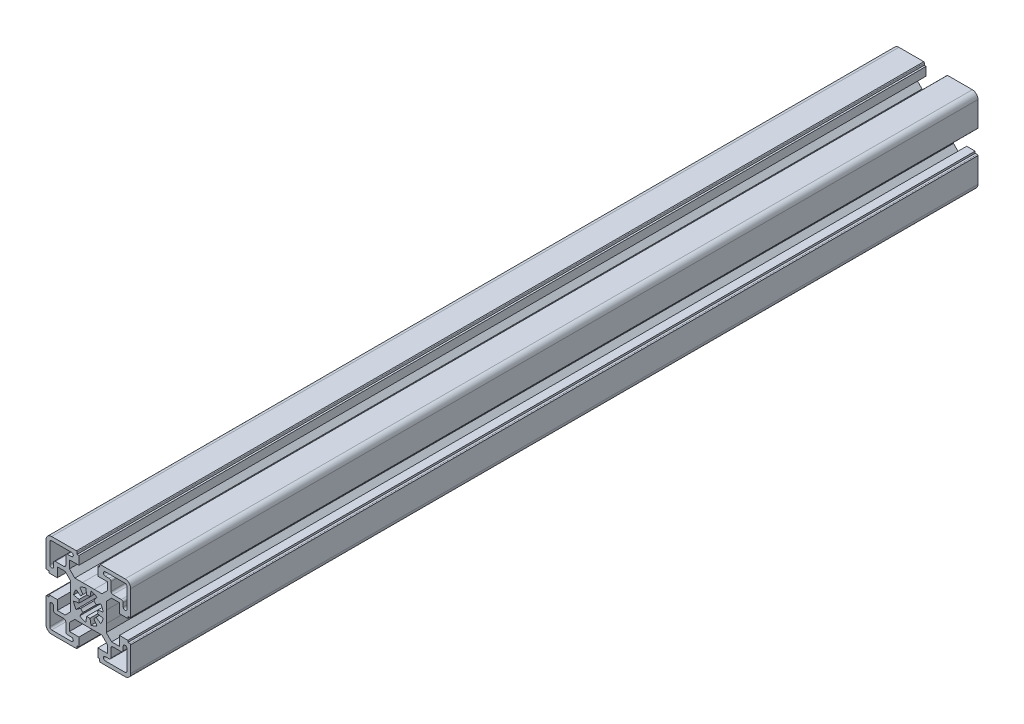
from build123d import *

# Parameters (mm, degrees)
BOSS_EXTRUDE1_DEPTH = 450


with BuildPart() as part:
    # Sketch1 → Boss-Extrude1 (new body)
    with BuildSketch(Plane.XY):
        with BuildLine():
            Line((-9.499953806, 3.122740916), (-9.499953806, 7.206970084))
            Line((-9.499953806, 7.206970084), (-12.342923806, 10.049940084))
            Line((-12.342923806, 10.049940084), (-16.500012806, 10.049940084))
            Line((-16.500012806, 10.049940084), (-16.500012806, 4.999940084))
            Line((-16.500012806, 4.999940084), (-20.999920806, 4.999940084))
            Line((-20.999920806, 4.999940084), (-20.999920806, 6))
            Line((-20.999920806, 6), (-21.99992119, 6))
            ThreePointArc((-21.99992119, 6), (-22.298164639, 6.069539801), (-22.49992067, 6.299929564))
            Line((-22.49992067, 6.299929564), (-22.49992067, 19.500002241))
            ThreePointArc((-22.49992067, 19.500002241), (-21.62124167, 21.621321), (-19.499922911, 22.5))
            Line((-19.499922911, 22.5), (-6.299954884, 22.5))
            ThreePointArc((-6.299954884, 22.5), (-6.069541349, 22.298205758), (-6, 21.999918456))
            Line((-6, 21.999918456), (-6, 20.999918083))
            Line((-6, 20.999918083), (-5, 20.999918083))
            Line((-5, 20.999918083), (-5, 16.499959846))
            Line((-5, 16.499959846), (-10.050086009, 16.499959846))
            Line((-10.050086009, 16.499959846), (-10.050086009, 12.342824291))
            Line((-10.050086009, 12.342824291), (-7.207137036, 9.499875319))
            Line((-7.207137036, 9.499875319), (-3.122784036, 9.499875319))
            Line((-3.122784036, 9.499875319), (3.122740916, 9.499953806))
            Line((3.122740916, 9.499953806), (7.206970084, 9.499953806))
            Line((7.206970084, 9.499953806), (10.049940084, 12.342923806))
            Line((10.049940084, 12.342923806), (10.049940084, 16.500012806))
            Line((10.049940084, 16.500012806), (4.999940084, 16.500012806))
            Line((4.999940084, 16.500012806), (4.999940084, 20.999920806))
            Line((4.999940084, 20.999920806), (6, 20.999920806))
            Line((6, 20.999920806), (6, 21.99992119))
            ThreePointArc((6, 21.99992119), (6.069539801, 22.298164639), (6.299929564, 22.49992067))
            Line((6.299929564, 22.49992067), (19.500002241, 22.49992067))
            ThreePointArc((19.500002241, 22.49992067), (21.621321, 21.62124167), (22.5, 19.499922911))
            Line((22.5, 19.499922911), (22.5, 6.299954884))
            ThreePointArc((22.5, 6.299954884), (22.298205758, 6.069541349), (21.999918456, 6))
            Line((21.999918456, 6), (20.999918083, 6))
            Line((20.999918083, 6), (20.999918083, 5))
            Line((20.999918083, 5), (16.499959846, 5))
            Line((16.499959846, 5), (16.499959846, 10.050086009))
            Line((16.499959846, 10.050086009), (12.342824291, 10.050086009))
            Line((12.342824291, 10.050086009), (9.499875319, 7.207137036))
            Line((9.499875319, 7.207137036), (9.499875319, 3.122784036))
            Line((9.499875319, 3.122784036), (9.499953806, -3.122740916))
            Line((9.499953806, -3.122740916), (9.499953806, -7.206970084))
            Line((9.499953806, -7.206970084), (12.342923806, -10.049940084))
            Line((12.342923806, -10.049940084), (16.500012806, -10.049940084))
            Line((16.500012806, -10.049940084), (16.500012806, -4.999940084))
            Line((16.500012806, -4.999940084), (20.999920806, -4.999940084))
            Line((20.999920806, -4.999940084), (20.999920806, -6))
            Line((20.999920806, -6), (21.99992119, -6))
            ThreePointArc((21.99992119, -6), (22.298164639, -6.069539801), (22.49992067, -6.299929564))
            Line((22.49992067, -6.299929564), (22.49992067, -19.500002241))
            ThreePointArc((22.49992067, -19.500002241), (21.62124167, -21.621321), (19.499922911, -22.5))
            Line((19.499922911, -22.5), (6.299954884, -22.5))
            ThreePointArc((6.299954884, -22.5), (6.069541349, -22.298205758), (6, -21.999918456))
            Line((6, -21.999918456), (6, -20.999918083))
            Line((6, -20.999918083), (5, -20.999918083))
            Line((5, -20.999918083), (5, -16.499959846))
            Line((5, -16.499959846), (10.050086009, -16.499959846))
            Line((10.050086009, -16.499959846), (10.050086009, -12.342824291))
            Line((10.050086009, -12.342824291), (7.207137036, -9.499875319))
            Line((7.207137036, -9.499875319), (3.122784036, -9.499875319))
            Line((3.122784036, -9.499875319), (-3.122740916, -9.499953806))
            Line((-3.122740916, -9.499953806), (-7.206970084, -9.499953806))
            Line((-7.206970084, -9.499953806), (-10.049940084, -12.342923806))
            Line((-10.049940084, -12.342923806), (-10.049940084, -16.500012806))
            Line((-10.049940084, -16.500012806), (-4.999940084, -16.500012806))
            Line((-4.999940084, -16.500012806), (-4.999940084, -20.999920806))
            Line((-4.999940084, -20.999920806), (-6, -20.999920806))
            Line((-6, -20.999920806), (-6, -21.99992119))
            ThreePointArc((-6, -21.99992119), (-6.069539801, -22.298164639), (-6.299929564, -22.49992067))
            Line((-6.299929564, -22.49992067), (-19.500002241, -22.49992067))
            ThreePointArc((-19.500002241, -22.49992067), (-21.621321, -21.62124167), (-22.5, -19.499922911))
            Line((-22.5, -19.499922911), (-22.5, -6.299954884))
            ThreePointArc((-22.5, -6.299954884), (-22.298205758, -6.069541349), (-21.999918456, -6))
            Line((-21.999918456, -6), (-20.999918083, -6))
            Line((-20.999918083, -6), (-20.999918083, -5))
            Line((-20.999918083, -5), (-16.499959846, -5))
            Line((-16.499959846, -5), (-16.499959846, -10.050086009))
            Line((-16.499959846, -10.050086009), (-12.342824291, -10.050086009))
            Line((-12.342824291, -10.050086009), (-9.499875319, -7.207137036))
            Line((-9.499875319, -7.207137036), (-9.499875319, -3.122784036))
            Line((-9.499875319, -3.122784036), (-9.499953806, 3.122740916))
        make_face()
        with BuildLine():
            Line((-4.588627311, 6.553189057), (-2.867885877, 4.095734317))
            ThreePointArc((-2.867885877, 4.095734317), (-3.535525782, 3.535515019), (-4.095743048, 2.867873408))
            Line((-4.095743048, 2.867873408), (-6.553203027, 4.588607361))
            ThreePointArc((-6.553203027, 4.588607361), (-7.391023494, 3.061463561), (-7.878449234, 1.389181447))
            Line((-7.878449234, 1.389181447), (-4.924020139, 0.868236529))
            ThreePointArc((-4.924020139, 0.868236529), (-4.9999809, 6.442e-06), (-4.924022376, -0.868223842))
            Line((-4.924022376, -0.868223842), (-7.878452813, -1.389161146))
            ThreePointArc((-7.878452813, -1.389161146), (-7.391022778, -3.061465289), (-6.553189057, -4.588627311))
            Line((-6.553189057, -4.588627311), (-4.095734317, -2.867885877))
            ThreePointArc((-4.095734317, -2.867885877), (-3.535515019, -3.535525782), (-2.867873408, -4.095743048))
            Line((-2.867873408, -4.095743048), (-4.588607361, -6.553203027))
            ThreePointArc((-4.588607361, -6.553203027), (-3.061463561, -7.391023494), (-1.389181447, -7.878449234))
            Line((-1.389181447, -7.878449234), (-0.868236529, -4.924020139))
            ThreePointArc((-0.868236529, -4.924020139), (-6.442e-06, -4.9999809), (0.868223842, -4.924022376))
            Line((0.868223842, -4.924022376), (1.389161146, -7.878452813))
            ThreePointArc((1.389161146, -7.878452813), (3.061465289, -7.391022778), (4.588627311, -6.553189057))
            Line((4.588627311, -6.553189057), (2.867885877, -4.095734317))
            ThreePointArc((2.867885877, -4.095734317), (3.535525782, -3.535515019), (4.095743048, -2.867873408))
            Line((4.095743048, -2.867873408), (6.553203027, -4.588607361))
            ThreePointArc((6.553203027, -4.588607361), (7.391023494, -3.061463561), (7.878449234, -1.389181447))
            Line((7.878449234, -1.389181447), (4.924020139, -0.868236529))
            ThreePointArc((4.924020139, -0.868236529), (4.9999809, -6.442e-06), (4.924022376, 0.868223842))
            Line((4.924022376, 0.868223842), (7.878452813, 1.389161146))
            ThreePointArc((7.878452813, 1.389161146), (7.391022778, 3.061465289), (6.553189057, 4.588627311))
            Line((6.553189057, 4.588627311), (4.095734317, 2.867885877))
            ThreePointArc((4.095734317, 2.867885877), (3.535515019, 3.535525782), (2.867873408, 4.095743048))
            Line((2.867873408, 4.095743048), (4.588607361, 6.553203027))
            ThreePointArc((4.588607361, 6.553203027), (3.061463561, 7.391023494), (1.389181447, 7.878449234))
            Line((1.389181447, 7.878449234), (0.868236529, 4.924020139))
            ThreePointArc((0.868236529, 4.924020139), (6.442e-06, 4.9999809), (-0.868223842, 4.924022376))
            Line((-0.868223842, 4.924022376), (-1.389161146, 7.878452813))
            ThreePointArc((-1.389161146, 7.878452813), (-3.061465289, 7.391022778), (-4.588627311, 6.553189057))
        make_face(mode=Mode.SUBTRACT)
        with BuildLine():
            Line((-17.500118733, 12.000017917), (-13.000117238, 12.000017917))
            ThreePointArc((-13.000117238, 12.000017917), (-12.293010986, 12.292910917), (-12.000117986, 13.00001717))
            Line((-12.000117986, 13.00001717), (-12.000117986, 17.49992083))
            ThreePointArc((-12.000117986, 17.49992083), (-11.707224986, 18.207027083), (-11.000118733, 18.499920083))
            Line((-11.000118733, 18.499920083), (-9.000117986, 18.499920083))
            ThreePointArc((-9.000117986, 18.499920083), (-8.000069069, 19.499969), (-9.000117986, 20.500017917))
            Line((-9.000117986, 20.500017917), (-19.500118733, 20.500017917))
            ThreePointArc((-19.500118733, 20.500017917), (-20.207224985, 20.207124917), (-20.500117986, 19.500018664))
            Line((-20.500117986, 19.500018664), (-20.500117986, 8.999920083))
            ThreePointArc((-20.500117986, 8.999920083), (-19.500117986, 7.999920083), (-18.500117985, 8.999920083))
            Line((-18.500117985, 8.999920083), (-18.500117985, 11.000018664))
            ThreePointArc((-18.500117985, 11.000018664), (-18.207224985, 11.707124917), (-17.500118733, 12.000017917))
        make_face(mode=Mode.SUBTRACT)
        with BuildLine():
            Line((12.000017917, 17.500118733), (12.000017917, 13.000117238))
            ThreePointArc((12.000017917, 13.000117238), (12.292910917, 12.293010986), (13.00001717, 12.000117986))
            Line((13.00001717, 12.000117986), (17.49992083, 12.000117986))
            ThreePointArc((17.49992083, 12.000117986), (18.207027083, 11.707224986), (18.499920083, 11.000118733))
            Line((18.499920083, 11.000118733), (18.499920083, 9.000117986))
            ThreePointArc((18.499920083, 9.000117986), (19.499969, 8.000069069), (20.500017917, 9.000117986))
            Line((20.500017917, 9.000117986), (20.500017917, 19.500118733))
            ThreePointArc((20.500017917, 19.500118733), (20.207124917, 20.207224985), (19.500018664, 20.500117985))
            Line((19.500018664, 20.500117985), (8.999920083, 20.500117985))
            ThreePointArc((8.999920083, 20.500117985), (7.999920083, 19.500117985), (8.999920083, 18.500117985))
            Line((8.999920083, 18.500117985), (11.000018664, 18.500117985))
            ThreePointArc((11.000018664, 18.500117985), (11.707124917, 18.207224985), (12.000017917, 17.500118733))
        make_face(mode=Mode.SUBTRACT)
        with BuildLine():
            Line((17.500118733, -12.000017917), (13.000117238, -12.000017917))
            ThreePointArc((13.000117238, -12.000017917), (12.293010986, -12.292910917), (12.000117986, -13.00001717))
            Line((12.000117986, -13.00001717), (12.000117986, -17.49992083))
            ThreePointArc((12.000117986, -17.49992083), (11.707224986, -18.207027083), (11.000118733, -18.499920083))
            Line((11.000118733, -18.499920083), (9.000117986, -18.499920083))
            ThreePointArc((9.000117986, -18.499920083), (8.000069069, -19.499969), (9.000117986, -20.500017917))
            Line((9.000117986, -20.500017917), (19.500118733, -20.500017917))
            ThreePointArc((19.500118733, -20.500017917), (20.207224985, -20.207124917), (20.500117985, -19.500018664))
            Line((20.500117985, -19.500018664), (20.500117985, -8.999920083))
            ThreePointArc((20.500117985, -8.999920083), (19.500117985, -7.999920083), (18.500117985, -8.999920083))
            Line((18.500117985, -8.999920083), (18.500117985, -11.000018664))
            ThreePointArc((18.500117985, -11.000018664), (18.207224985, -11.707124917), (17.500118733, -12.000017917))
        make_face(mode=Mode.SUBTRACT)
        with BuildLine():
            Line((-12.000017917, -17.500118733), (-12.000017917, -13.000117238))
            ThreePointArc((-12.000017917, -13.000117238), (-12.292910917, -12.293010986), (-13.00001717, -12.000117986))
            Line((-13.00001717, -12.000117986), (-17.49992083, -12.000117986))
            ThreePointArc((-17.49992083, -12.000117986), (-18.207027083, -11.707224986), (-18.499920083, -11.000118733))
            Line((-18.499920083, -11.000118733), (-18.499920083, -9.000117986))
            ThreePointArc((-18.499920083, -9.000117986), (-19.499969, -8.000069069), (-20.500017917, -9.000117986))
            Line((-20.500017917, -9.000117986), (-20.500017917, -19.500118733))
            ThreePointArc((-20.500017917, -19.500118733), (-20.207124917, -20.207224985), (-19.500018664, -20.500117985))
            Line((-19.500018664, -20.500117985), (-8.999920083, -20.500117985))
            ThreePointArc((-8.999920083, -20.500117985), (-7.999920083, -19.500117985), (-8.999920083, -18.500117985))
            Line((-8.999920083, -18.500117985), (-11.000018664, -18.500117985))
            ThreePointArc((-11.000018664, -18.500117985), (-11.707124917, -18.207224985), (-12.000017917, -17.500118733))
        make_face(mode=Mode.SUBTRACT)
    extrude(amount=BOSS_EXTRUDE1_DEPTH)


solid = part.part
